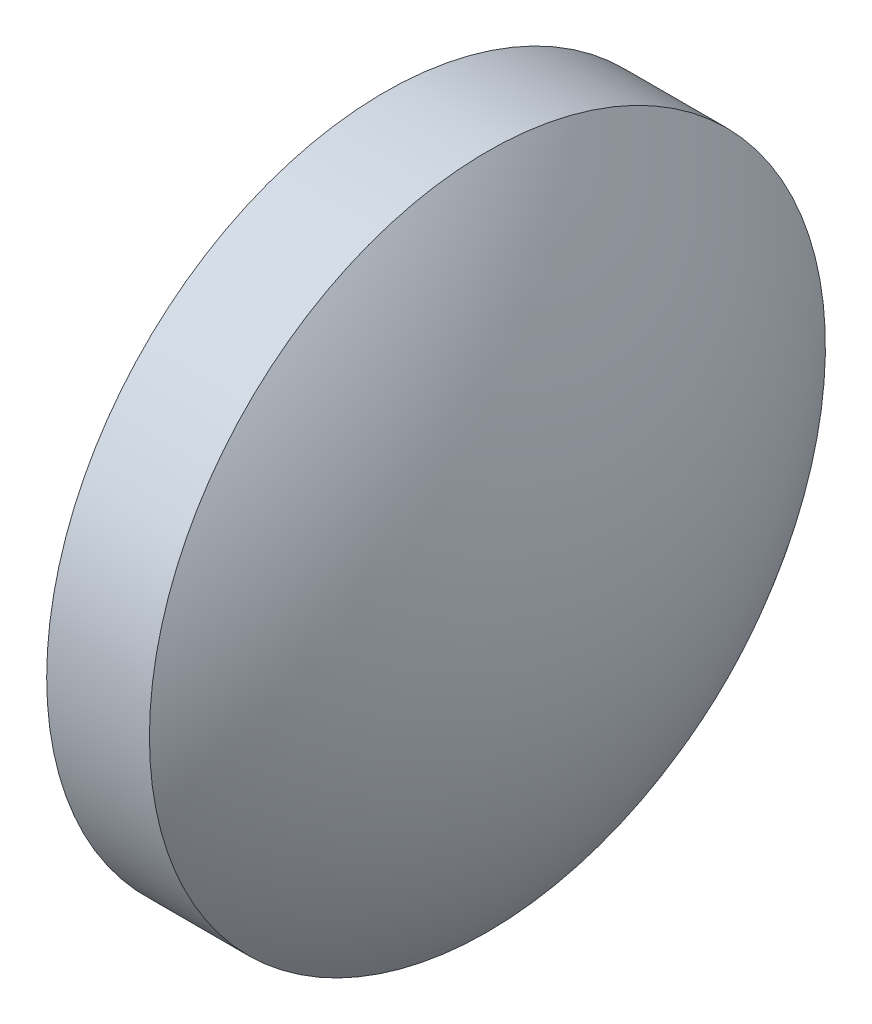
from build123d import *


with BuildPart() as part:
    # 草图2 → 旋转2 (revolve)
    with BuildSketch(Plane.XY, mode=Mode.PRIVATE) as revolve_2_sk:
        with BuildLine():
            Line((523.005648253, 17.054615163), (523.005648253, 22.054615163))
            Line((523.005648253, 22.054615163), (524.525648253, 22.054615163))
            ThreePointArc((524.525648253, 22.054615163), (525.774419538, 19.691962315), (526.205648253, 17.054615163))
            Line((526.205648253, 17.054615163), (523.005648253, 17.054615163))
        make_face()
    revolve(revolve_2_sk.sketch.rotate(Axis((522.207975998, 17.054615163, 0), (1, 0, 0)), 180), axis=Axis((522.207975998, 17.054615163, 0), (1, 0, 0)))  # turned: the seam where the file's is


solid = part.part
